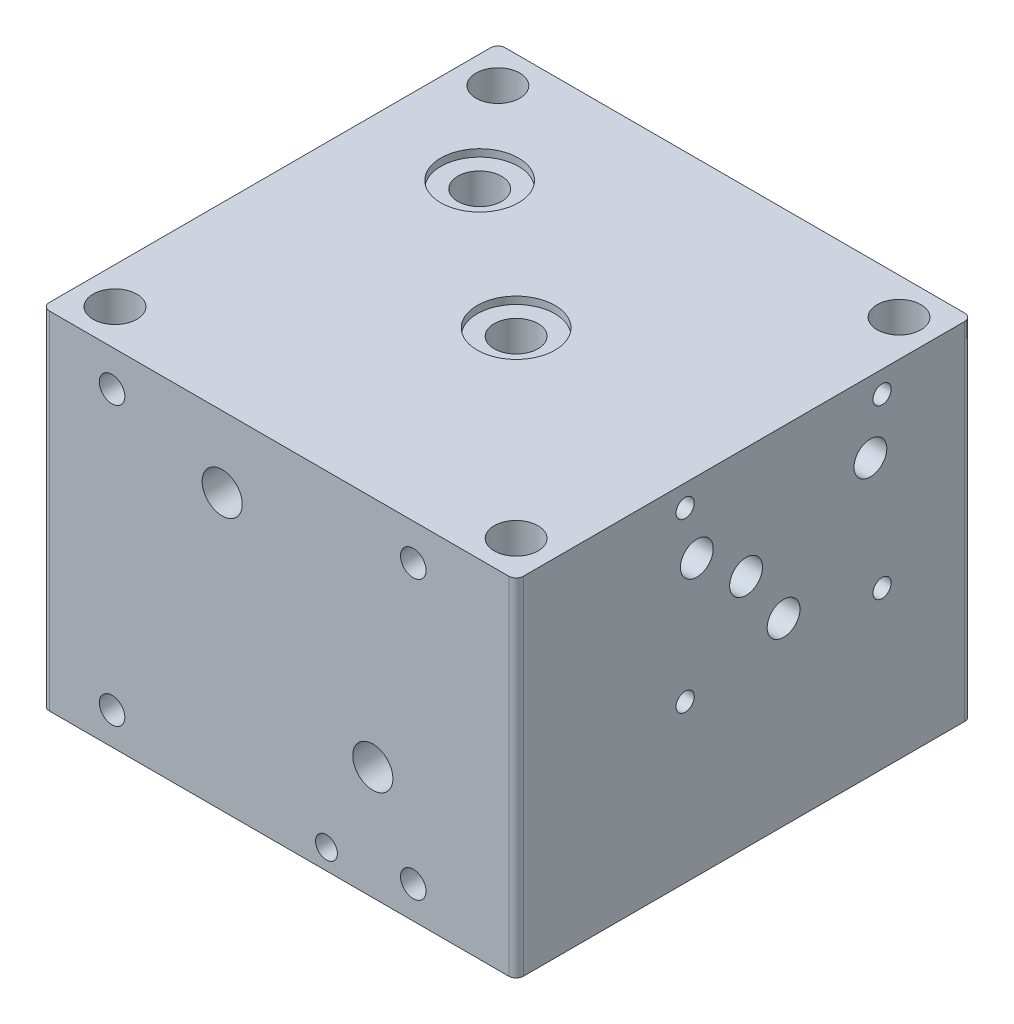
from build123d import *

# Parameters (mm, degrees)
SKETCH_1_W             = 130
SKETCH_1_H             = 125
EXTRUDE_1_DEPTH        = 100
FILLET_1_R             = 2
SKETCH_2_R             = 6
CUT_EXTRUDE_1_DEPTH    = 135.652330095
SKETCH_3_R             = 6
CUT_EXTRUDE_2_DEPTH    = 135.652330095
SKETCH_6_R             = 11.5
CUT_EXTRUDE_3_DEPTH    = 2
MM_8_D                 = 9
MM_8_DEPTH             = 68
MM_8_TIP               = 2.703872786
MM_8_2_D               = 9
MM_8_2_DEPTH           = 35
MM_8_2_TIP             = 2.703872786
MM_11_D                = 8
MM_11_DEPTH            = 90
MM_11_TIP              = 2.403442476
MM_8_3_D               = 9
MM_8_3_DEPTH           = 88
MM_8_3_TIP             = 2.703872786
MM_8_4_D               = 11
MM_8_4_DEPTH           = 50
MM_8_4_TIP             = 3.304733405
MM_14_D                = 11
MM_14_DEPTH            = 93
MM_14_TIP              = 3.304733405
MM_8_5_D               = 9
MM_8_5_DEPTH           = 85
MM_8_5_TIP             = 2.703872786
MM_10_D                = 9
MM_10_DEPTH            = 80
MM_10_TIP              = 2.703872786
MM_10_2_D              = 9
MM_10_2_DEPTH          = 55
MM_10_2_TIP            = 2.703872786
MM_11_2_D              = 8
MM_11_2_DEPTH          = 60
MM_11_2_TIP            = 2.403442476
MM_12_D                = 9
MM_12_DEPTH            = 38
MM_12_TIP              = 2.703872786
MM_13_REACH            = 174.772
MM_13_BORE_R           = 4
M10X1_0_1_D            = 9
M10X1_0_1_DEPTH        = 10
M10X1_0_1_TIP          = 2.703872786
MM_14_2_D              = 6
MM_14_2_DEPTH          = 12
MM_14_2_TIP            = 1.802581857
SKETCH_46_R            = 6
EXTRUDE_2_DEPTH        = 1
SKETCH_47_W            = 130
SKETCH_47_H            = 6
CUT_EXTRUDE_4_DEPTH    = 173.771525469
SKETCH_48_R            = 10.65
CUT_EXTRUDE_5_DEPTH    = 2
HOLE_WIZARD_M6_1_D     = 5
HOLE_WIZARD_M6_1_DEPTH = 10
HOLE_WIZARD_M6_1_TIP   = 1.502151548
HOLE_WIZARD_M6_2_D     = 5
HOLE_WIZARD_M6_2_DEPTH = 10
HOLE_WIZARD_M6_2_TIP   = 1.502151548
M8X1_0_1_D             = 7
M8X1_0_1_DEPTH         = 10
M8X1_0_1_TIP           = 2.103012167


with BuildPart() as part:
    # 草图1 → 凸台-拉伸1 (new body)
    with BuildSketch(Plane(origin=(0, 0, 0), x_dir=(1, 0, 0), z_dir=(0, 1, 0))):
        Rectangle(SKETCH_1_W, SKETCH_1_H)
    extrude(amount=EXTRUDE_1_DEPTH)

    # 圆角1
    fillet_1_edges = [part.edges().sort_by_distance(p)[0] for p in [
        (65, 50, 62.5),
        (-65, 50, 62.5),
        (-65, 50, -62.5),
        (65, 50, -62.5),
    ]]
    fillet(fillet_1_edges, radius=FILLET_1_R)

    # 草图2 → 切除-拉伸1 (cut, through all)
    with BuildSketch(Plane(origin=(0, 100, 0), x_dir=(1, 0, 0), z_dir=(0, 1, 0))):
        with Locations(Location((55, 52.5, 0), (0, 0, 270))):
            Circle(SKETCH_2_R)
        with Locations(Location((55, -52.5, 0), (0, 0, 270))):
            Circle(SKETCH_2_R)
        with Locations(Location((-55, 52.5, 0), (0, 0, 270))):
            Circle(SKETCH_2_R)
        with Locations(Location((-55, -52.5, 0), (0, 0, 270))):
            Circle(SKETCH_2_R)
    extrude(amount=-CUT_EXTRUDE_1_DEPTH, mode=Mode.SUBTRACT)

    # 草图3 → 切除-拉伸2 (cut, through all)
    with BuildSketch(Plane(origin=(0, 100, 0), x_dir=(1, 0, 0), z_dir=(0, 1, 0))):
        with Locations(Location((-35, 27.5, 0), (0, 0, 270))):
            Circle(SKETCH_3_R)
        with Locations(Location((5, -2.5, 0), (0, 0, 270))):
            Circle(SKETCH_3_R)
    extrude(amount=-CUT_EXTRUDE_2_DEPTH, mode=Mode.SUBTRACT)

    # 草图6 → 切除-拉伸3 (cut)
    with BuildSketch(Plane(origin=(0, 100, 0), x_dir=(1, 0, 0), z_dir=(0, 1, 0))):
        with Locations(Location((5, -2.5, 0), (0, 0, 270))):
            Circle(SKETCH_6_R)
        with Locations(Location((-35, 27.5, 0), (0, 0, 270))):
            Circle(SKETCH_6_R)
    extrude(amount=-CUT_EXTRUDE_3_DEPTH, mode=Mode.SUBTRACT)

    # mm _8
    with Locations(Plane.ZY.offset(65)):
        with Locations((5.5, 50.7)):
            Hole(MM_8_D / 2, depth=MM_8_DEPTH)
            with Locations((0, 0, -(MM_8_DEPTH + MM_8_TIP / 2))):  # 118° drill point
                Cone(0, MM_8_D / 2, MM_8_TIP, mode=Mode.SUBTRACT)

    # mm _8 2
    with Locations(Plane.ZY.offset(65)):
        with Locations((-18.3, 24.5), (29.3, 24.5)):
            Hole(MM_8_2_D / 2, depth=MM_8_2_DEPTH)
            with Locations((0, 0, -(MM_8_2_DEPTH + MM_8_2_TIP / 2))):  # 118° drill point
                Cone(0, MM_8_2_D / 2, MM_8_2_TIP, mode=Mode.SUBTRACT)

    # mm _11
    with Locations(Plane(origin=(0, 0, -62.5), x_dir=(-1, 0, 0), z_dir=(0, 0, -1))):
        with Locations((34.837807322, 24.5)):
            Hole(MM_11_D / 2, depth=MM_11_DEPTH)
            with Locations((0, 0, -(MM_11_DEPTH + MM_11_TIP / 2))):  # 118° drill point
                Cone(0, MM_11_D / 2, MM_11_TIP, mode=Mode.SUBTRACT)

    # mm _8 3
    with Locations(Plane.ZY.offset(65)):
        with Locations((15.8, 35.6)):
            Hole(MM_8_3_D / 2, depth=MM_8_3_DEPTH)
            with Locations((0, 0, -(MM_8_3_DEPTH + MM_8_3_TIP / 2))):  # 118° drill point
                Cone(0, MM_8_3_D / 2, MM_8_3_TIP, mode=Mode.SUBTRACT)

    # mm _8 4
    with Locations(Plane.XY.offset(62.5)):
        with Locations((25.703872786, 30.023764132)):
            Hole(MM_8_4_D / 2, depth=MM_8_4_DEPTH)
            with Locations((0, 0, -(MM_8_4_DEPTH + MM_8_4_TIP / 2))):  # 118° drill point
                Cone(0, MM_8_4_D / 2, MM_8_4_TIP, mode=Mode.SUBTRACT)

    # mm _14
    with Locations(Plane.XY.offset(62.5)):
        with Locations((-15.596127214, 74.523764132)):
            Hole(MM_14_D / 2, depth=MM_14_DEPTH)
            with Locations((0, 0, -(MM_14_DEPTH + MM_14_TIP / 2))):  # 118° drill point
                Cone(0, MM_14_D / 2, MM_14_TIP, mode=Mode.SUBTRACT)

    # mm _8 5
    with Locations(Plane(origin=(65, 0, 0), x_dir=(0, 0, -1), z_dir=(1, 0, 0))):
        with Locations((-12.950517883, 74.523764132), (34.649482117, 74.523764132)):
            Hole(MM_8_5_D / 2, depth=MM_8_5_DEPTH)
            with Locations((0, 0, -(MM_8_5_DEPTH + MM_8_5_TIP / 2))):  # 118° drill point
                Cone(0, MM_8_5_D / 2, MM_8_5_TIP, mode=Mode.SUBTRACT)

    # mm _10
    with Locations(Plane(origin=(65, 0, 0), x_dir=(0, 0, -1), z_dir=(1, 0, 0))):
        with Locations((10.849482117, 48.323764132)):
            Hole(MM_10_D / 2, depth=MM_10_DEPTH)
            with Locations((0, 0, -(MM_10_DEPTH + MM_10_TIP / 2))):  # 118° drill point
                Cone(0, MM_10_D / 2, MM_10_TIP, mode=Mode.SUBTRACT)

    # mm _10 2
    with Locations(Plane.ZY.offset(65)):
        with Locations((-4.8, 35.6)):
            Hole(MM_10_2_D / 2, depth=MM_10_2_DEPTH)
            with Locations((0, 0, -(MM_10_2_DEPTH + MM_10_2_TIP / 2))):  # 118° drill point
                Cone(0, MM_10_2_D / 2, MM_10_2_TIP, mode=Mode.SUBTRACT)

    # mm _11 2
    with Locations(Plane(origin=(0, 0, -62.5), x_dir=(-1, 0, 0), z_dir=(0, 0, -1))):
        with Locations((13.327113154, 41.821108308)):
            Hole(MM_11_2_D / 2, depth=MM_11_2_DEPTH)
            with Locations((0, 0, -(MM_11_2_DEPTH + MM_11_2_TIP / 2))):  # 118° drill point
                Cone(0, MM_11_2_D / 2, MM_11_2_TIP, mode=Mode.SUBTRACT)

    # 大小mm 暗销孔12
    with Locations(Plane(origin=(65, 0, 0), x_dir=(0, 0, -1), z_dir=(1, 0, 0))):
        with Locations((0.549482117, 63.423764132)):
            Hole(MM_12_D / 2, depth=MM_12_DEPTH)
            with Locations((0, 0, -(MM_12_DEPTH + MM_12_TIP / 2))):  # 118° drill point
                Cone(0, MM_12_D / 2, MM_12_TIP, mode=Mode.SUBTRACT)

    # 大小mm 暗销孔13 bore → 大小mm 暗销孔13 (cut, up to next)
    with BuildSketch(Plane(origin=(0, 0, -62.5), x_dir=(-1, 0, 0), z_dir=(0, 0, -1)), mode=Mode.PRIVATE) as mm_13_sk1:
        with Locations((-31.919174633, 63.214193883)):
            Circle(MM_13_BORE_R)
    mm_13_tool1 = extrude(mm_13_sk1.sketch, amount=-MM_13_REACH, mode=Mode.PRIVATE) & part.part
    add(mm_13_tool1.solids().sort_by_distance((31.919175, 63.214194, -62.5))[0], mode=Mode.SUBTRACT)

    # M10x1.0 螺纹孔1
    with Locations(Plane(origin=(0, 0, -62.5), x_dir=(-1, 0, 0), z_dir=(0, 0, -1))):
        with Locations((34.837807322, 24.5), (13.327113154, 41.821108308), (-31.919174633, 63.214193883)):
            Hole(M10X1_0_1_D / 2, depth=M10X1_0_1_DEPTH)
            with Locations((0, 0, -(M10X1_0_1_DEPTH + M10X1_0_1_TIP / 2))):  # 118° drill point
                Cone(0, M10X1_0_1_D / 2, M10X1_0_1_TIP, mode=Mode.SUBTRACT)

    # mm _14 2
    with Locations(Plane.XY.offset(62.5)):
        with Locations((13.003872786, 4.623764132)):
            Hole(MM_14_2_D / 2, depth=MM_14_2_DEPTH)
            with Locations((0, 0, -(MM_14_2_DEPTH + MM_14_2_TIP / 2))):  # 118° drill point
                Cone(0, MM_14_2_D / 2, MM_14_2_TIP, mode=Mode.SUBTRACT)

    # 草图46 → 凸台-拉伸2 (add)
    with BuildSketch(Plane.XZ):
        with BuildLine():
            Line((63, 62.5), (-63, 62.5))
            ThreePointArc((-63, 62.5), (-64.414213562, 61.914213562), (-65, 60.5))
            Line((-65, 60.5), (-65, -60.5))
            ThreePointArc((-65, -60.5), (-64.414213562, -61.914213562), (-63, -62.5))
            Line((-63, -62.5), (63, -62.5))
            ThreePointArc((63, -62.5), (64.414213562, -61.914213562), (65, -60.5))
            Line((65, -60.5), (65, 60.5))
            ThreePointArc((65, 60.5), (64.414213562, 61.914213562), (63, 62.5))
        make_face()
        with Locations(Location((5, 2.5, 0), (0, 0, 90))):
            Circle(SKETCH_46_R, mode=Mode.SUBTRACT)
        with Locations(Location((-35, -27.5, 0), (0, 0, 90))):
            Circle(SKETCH_46_R, mode=Mode.SUBTRACT)
        with Locations(Location((-55, -52.5, 0), (0, 0, 90))):
            Circle(SKETCH_46_R, mode=Mode.SUBTRACT)
        with Locations(Location((55, -52.5, 0), (0, 0, 90))):
            Circle(SKETCH_46_R, mode=Mode.SUBTRACT)
        with Locations(Location((55, 52.5, 0), (0, 0, 90))):
            Circle(SKETCH_46_R, mode=Mode.SUBTRACT)
        with Locations(Location((-55, 52.5, 0), (0, 0, 90))):
            Circle(SKETCH_46_R, mode=Mode.SUBTRACT)
    extrude(amount=EXTRUDE_2_DEPTH)

    # 草图47 → 切除-拉伸4 (cut, through all)
    with BuildSketch(Plane.XY.offset(62.5)):
        with Locations((0, 97)):
            Rectangle(SKETCH_47_W, SKETCH_47_H)
    extrude(amount=-CUT_EXTRUDE_4_DEPTH, mode=Mode.SUBTRACT)

    # 草图48 → 切除-拉伸5 (cut)
    with BuildSketch(Plane(origin=(0, 94, 0), x_dir=(1, 0, 0), z_dir=(0, 1, 0))):
        with Locations(Location((5, -2.5, 0), (0, 0, 270))):
            Circle(SKETCH_48_R)
        with Locations(Location((-35, 27.5, 0), (0, 0, 270))):
            Circle(SKETCH_48_R)
    extrude(amount=-CUT_EXTRUDE_5_DEPTH, mode=Mode.SUBTRACT)

    # M6 螺纹孔1
    with Locations(Plane.ZY.offset(65)):
        with Locations((32.5, 57), (32.5, 12), (-21.5, 12), (-21.5, 57)):
            Hole(HOLE_WIZARD_M6_1_D / 2, depth=HOLE_WIZARD_M6_1_DEPTH)
            with Locations((0, 0, -(HOLE_WIZARD_M6_1_DEPTH + HOLE_WIZARD_M6_1_TIP / 2))):  # 118° drill point
                Cone(0, HOLE_WIZARD_M6_1_D / 2, HOLE_WIZARD_M6_1_TIP, mode=Mode.SUBTRACT)

    # M6 螺纹孔2
    with Locations(Plane(origin=(65, 0, 0), x_dir=(0, 0, -1), z_dir=(1, 0, 0))):
        with Locations((37.849482117, 88.023764132), (-16.150517883, 88.023764132), (-16.150517883, 42.023764132), (37.849482117, 42.023764132)):
            Hole(HOLE_WIZARD_M6_2_D / 2, depth=HOLE_WIZARD_M6_2_DEPTH)
            with Locations((0, 0, -(HOLE_WIZARD_M6_2_DEPTH + HOLE_WIZARD_M6_2_TIP / 2))):  # 118° drill point
                Cone(0, HOLE_WIZARD_M6_2_D / 2, HOLE_WIZARD_M6_2_TIP, mode=Mode.SUBTRACT)

    # M8x1.0 螺纹孔1
    with Locations(Plane.XY.offset(62.5)):
        with Locations((36.803872786, 7.823764132), (36.803872786, 84.023764132), (-45.796127214, 84.023764132), (-45.796127214, 7.823764132)):
            Hole(M8X1_0_1_D / 2, depth=M8X1_0_1_DEPTH)
            with Locations((0, 0, -(M8X1_0_1_DEPTH + M8X1_0_1_TIP / 2))):  # 118° drill point
                Cone(0, M8X1_0_1_D / 2, M8X1_0_1_TIP, mode=Mode.SUBTRACT)


solid = part.part
